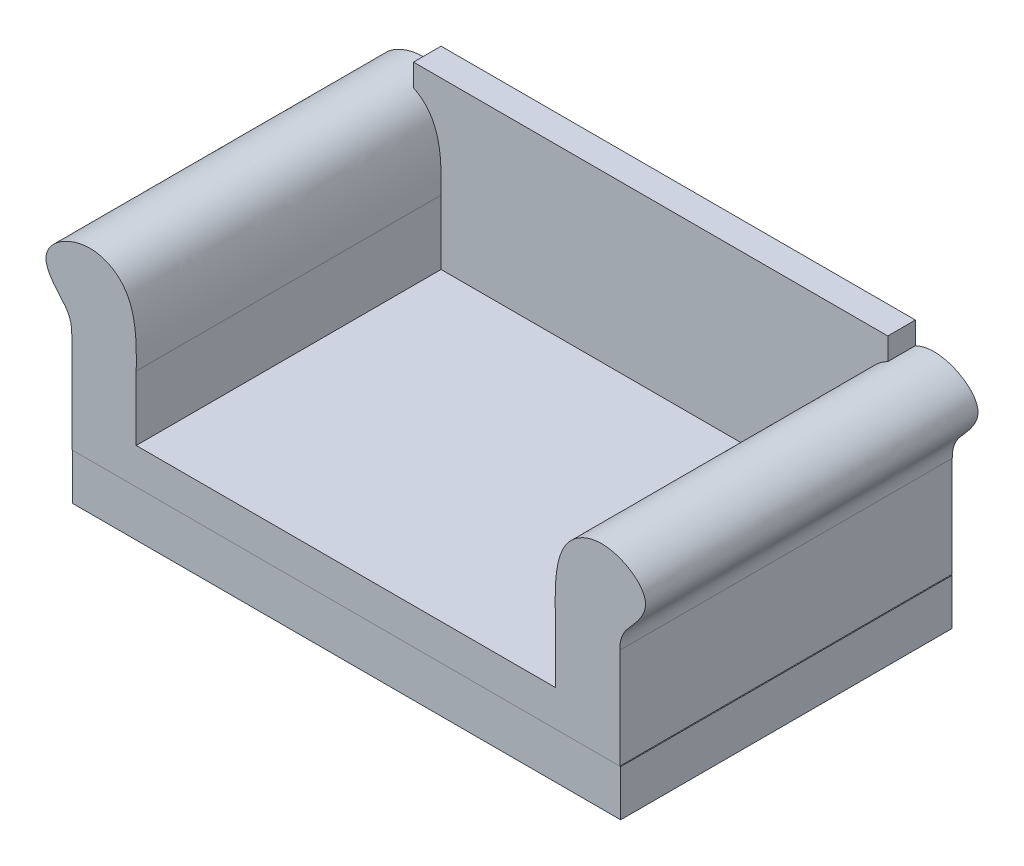
from build123d import *

# Parameters (mm, degrees)
SKETCH1_W           = 88.9
SKETCH1_H           = 914.4
SKETCH1_W_2         = 25.4
SKETCH1_H_2         = 863.6
BOSS_EXTRUDE1_DEPTH = 127
BOSS_EXTRUDE3_DEPTH = 916.94
SKETCH5_W           = 1308.1
SKETCH5_H           = 76.2
BOSS_EXTRUDE4_DEPTH = 457.2


with BuildPart() as part:
    # Sketch1 → Boss-Extrude1 (new body)
    with BuildSketch(Plane(origin=(0, 0, 0), x_dir=(1, 0, 0), z_dir=(0, 1, 0))):
        with Locations((-711.2, 0)):
            Rectangle(SKETCH1_W, SKETCH1_H)
        Polygon((-666.75, -431.8), (-666.75, -457.2), (666.75, -457.2), (666.75, -431.8), (57.15, -431.8), (31.75, -431.8), align=None)
        with Locations((711.2, 0)):
            Rectangle(SKETCH1_W, SKETCH1_H)
        Polygon((666.75, 457.2), (-666.75, 457.2), (-666.75, 431.8), (31.75, 431.8), (57.15, 431.8), (666.75, 431.8), align=None)
        with Locations((44.45, 0)):
            Rectangle(SKETCH1_W_2, SKETCH1_H_2)
    extrude(amount=BOSS_EXTRUDE1_DEPTH)


with BuildPart() as body_2:
    # Sketch4 → Boss-Extrude3 (new body)
    with BuildSketch(Plane.XY.offset(459.74)):
        with BuildLine():
            Line((-755.65, 129.54), (755.65, 129.54))
            Line((755.65, 129.54), (755.65, 406.4))
            add(Edge.make_bspline(
                [(755.65, 406.4), (755.65, 451.087278401), (791.216850954, 477.433435736), (855.398910121, 573.852472449), (720.303655557, 663.232501149), (568.867733776, 589.838855636), (577.85, 447.650661263), (577.85, 406.4)],
                knots=[0, 0, 0, 0, 0.157242683, 0.266642819, 0.492649097, 0.701571925, 1, 1, 1, 1], degree=3))
            Line((577.85, 406.4), (577.85, 228.6))
            Line((577.85, 228.6), (-577.85, 228.6))
            Line((-577.85, 228.6), (-577.85, 406.4))
            add(Edge.make_bspline(
                [(-755.65, 406.4), (-755.65, 451.087278401), (-791.216850954, 477.433435736), (-855.398910121, 573.852472449), (-720.303655557, 663.232501149), (-568.867733776, 589.838855636), (-577.85, 447.650661263), (-577.85, 406.4)],
                knots=[0, 0, 0, 0, 0.157242683, 0.266642819, 0.492649097, 0.701571925, 1, 1, 1, 1], degree=3))
            Line((-755.65, 406.4), (-755.65, 129.54))
        make_face()
    extrude(amount=-BOSS_EXTRUDE3_DEPTH)

    # Sketch5 → Boss-Extrude4 (add)
    with BuildSketch(Plane(origin=(0, 228.6, 0), x_dir=(1, 0, 0), z_dir=(0, 1, 0))):
        with Locations((0, 419.1)):
            Rectangle(SKETCH5_W, SKETCH5_H)
    extrude(amount=BOSS_EXTRUDE4_DEPTH)


solid = Compound([part.part, body_2.part])
